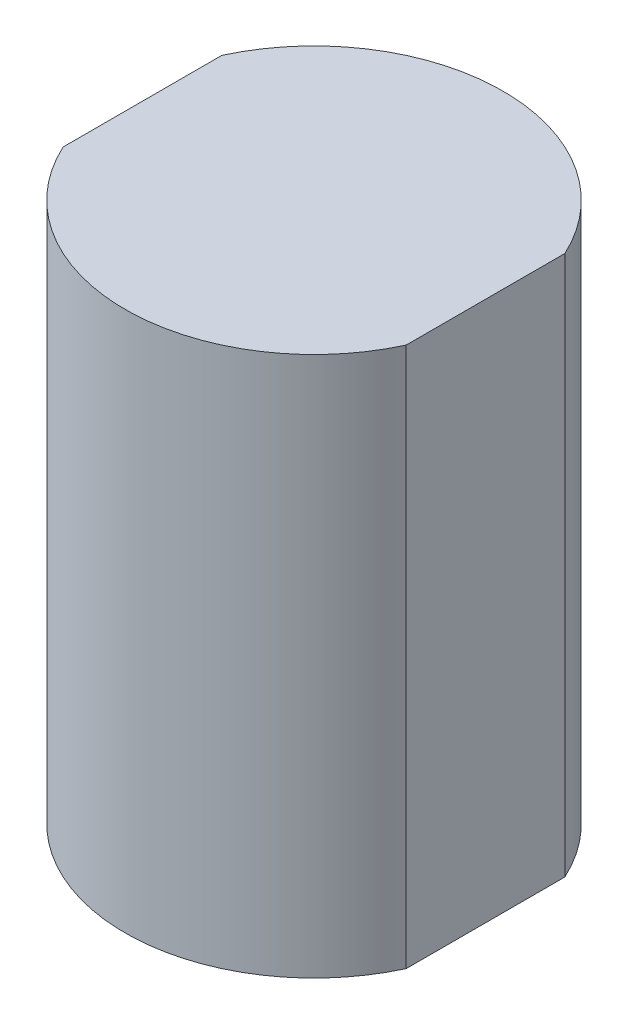
from build123d import *

# Parameters (mm, degrees)
BOSS_EXTRUDE1_DEPTH = 10


with BuildPart() as part:
    # Sketch1 → Boss-Extrude1 (new body)
    with BuildSketch(Plane(origin=(0, 0, 0), x_dir=(1, 0, 0), z_dir=(0, 1, 0))):
        with BuildLine():
            Line((-3.176334365, 1.47), (-3.176334365, -1.47))
            ThreePointArc((-3.176334365, -1.47), (0, -3.5), (3.176334365, -1.47))
            Line((3.176334365, -1.47), (3.176334365, 1.47))
            ThreePointArc((3.176334365, 1.47), (0, 3.5), (-3.176334365, 1.47))
        make_face()
    extrude(amount=BOSS_EXTRUDE1_DEPTH)


solid = part.part
